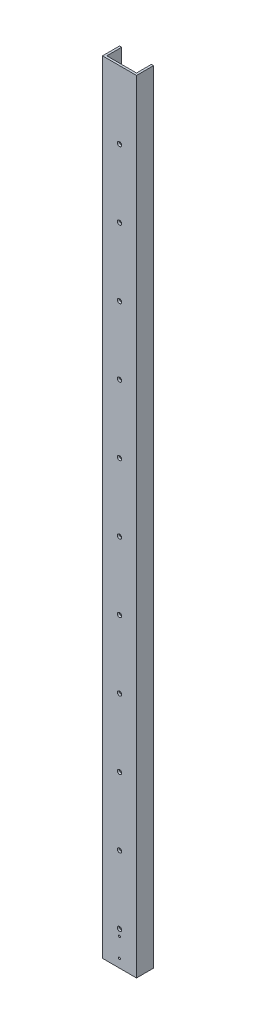
from build123d import *

# Parameters (mm, degrees)
BOSS_EXTRUDE1_DEPTH = 1168.4
CUT_EXTRUDE1_REACH  = 27.4
SKETCH2_R           = 3.175
CUT_EXTRUDE2_REACH  = 27.4
SKETCH4_R           = 1.5875


with BuildPart() as part:
    # Sketch1 → Boss-Extrude1 (new body)
    with BuildSketch(Plane(origin=(0, 0, 0), x_dir=(1, 0, 0), z_dir=(0, 1, 0))):
        Polygon((3.175, 3.175), (3.175, 25.4), (0, 25.4), (0, 0), (50.8, 0), (50.8, 25.4), (47.625, 25.4), (47.625, 3.175), align=None)
    extrude(amount=BOSS_EXTRUDE1_DEPTH)

    # Sketch2 → Cut-Extrude1 (cut, up to next)
    with BuildSketch(Plane.XY, mode=Mode.PRIVATE) as cut_extrude1_sk1:
        with Locations((25.4, 50.8)):
            Circle(SKETCH2_R)
    cut_extrude1_tool1 = extrude(cut_extrude1_sk1.sketch, amount=-CUT_EXTRUDE1_REACH, mode=Mode.PRIVATE) & part.part
    add(cut_extrude1_tool1.solids().sort_by_distance((25.4, 50.8, 0))[0], mode=Mode.SUBTRACT)
    # Sketch2 → Cut-Extrude1 (cut, up to next)
    with BuildSketch(Plane.XY, mode=Mode.PRIVATE) as cut_extrude1_sk2:
        with Locations((25.4, 152.4)):
            Circle(SKETCH2_R)
    cut_extrude1_tool2 = extrude(cut_extrude1_sk2.sketch, amount=-CUT_EXTRUDE1_REACH, mode=Mode.PRIVATE) & part.part
    add(cut_extrude1_tool2.solids().sort_by_distance((25.4, 152.4, 0))[0], mode=Mode.SUBTRACT)
    # Sketch2 → Cut-Extrude1 (cut, up to next)
    with BuildSketch(Plane.XY, mode=Mode.PRIVATE) as cut_extrude1_sk3:
        with Locations((25.4, 254)):
            Circle(SKETCH2_R)
    cut_extrude1_tool3 = extrude(cut_extrude1_sk3.sketch, amount=-CUT_EXTRUDE1_REACH, mode=Mode.PRIVATE) & part.part
    add(cut_extrude1_tool3.solids().sort_by_distance((25.4, 254, 0))[0], mode=Mode.SUBTRACT)
    # Sketch2 → Cut-Extrude1 (cut, up to next)
    with BuildSketch(Plane.XY, mode=Mode.PRIVATE) as cut_extrude1_sk4:
        with Locations((25.4, 355.6)):
            Circle(SKETCH2_R)
    cut_extrude1_tool4 = extrude(cut_extrude1_sk4.sketch, amount=-CUT_EXTRUDE1_REACH, mode=Mode.PRIVATE) & part.part
    add(cut_extrude1_tool4.solids().sort_by_distance((25.4, 355.6, 0))[0], mode=Mode.SUBTRACT)
    # Sketch2 → Cut-Extrude1 (cut, up to next)
    with BuildSketch(Plane.XY, mode=Mode.PRIVATE) as cut_extrude1_sk5:
        with Locations((25.4, 457.2)):
            Circle(SKETCH2_R)
    cut_extrude1_tool5 = extrude(cut_extrude1_sk5.sketch, amount=-CUT_EXTRUDE1_REACH, mode=Mode.PRIVATE) & part.part
    add(cut_extrude1_tool5.solids().sort_by_distance((25.4, 457.2, 0))[0], mode=Mode.SUBTRACT)
    # Sketch2 → Cut-Extrude1 (cut, up to next)
    with BuildSketch(Plane.XY, mode=Mode.PRIVATE) as cut_extrude1_sk6:
        with Locations((25.4, 558.8)):
            Circle(SKETCH2_R)
    cut_extrude1_tool6 = extrude(cut_extrude1_sk6.sketch, amount=-CUT_EXTRUDE1_REACH, mode=Mode.PRIVATE) & part.part
    add(cut_extrude1_tool6.solids().sort_by_distance((25.4, 558.8, 0))[0], mode=Mode.SUBTRACT)
    # Sketch2 → Cut-Extrude1 (cut, up to next)
    with BuildSketch(Plane.XY, mode=Mode.PRIVATE) as cut_extrude1_sk7:
        with Locations((25.4, 660.4)):
            Circle(SKETCH2_R)
    cut_extrude1_tool7 = extrude(cut_extrude1_sk7.sketch, amount=-CUT_EXTRUDE1_REACH, mode=Mode.PRIVATE) & part.part
    add(cut_extrude1_tool7.solids().sort_by_distance((25.4, 660.4, 0))[0], mode=Mode.SUBTRACT)
    # Sketch2 → Cut-Extrude1 (cut, up to next)
    with BuildSketch(Plane.XY, mode=Mode.PRIVATE) as cut_extrude1_sk8:
        with Locations((25.4, 762)):
            Circle(SKETCH2_R)
    cut_extrude1_tool8 = extrude(cut_extrude1_sk8.sketch, amount=-CUT_EXTRUDE1_REACH, mode=Mode.PRIVATE) & part.part
    add(cut_extrude1_tool8.solids().sort_by_distance((25.4, 762, 0))[0], mode=Mode.SUBTRACT)
    # Sketch2 → Cut-Extrude1 (cut, up to next)
    with BuildSketch(Plane.XY, mode=Mode.PRIVATE) as cut_extrude1_sk9:
        with Locations((25.4, 863.6)):
            Circle(SKETCH2_R)
    cut_extrude1_tool9 = extrude(cut_extrude1_sk9.sketch, amount=-CUT_EXTRUDE1_REACH, mode=Mode.PRIVATE) & part.part
    add(cut_extrude1_tool9.solids().sort_by_distance((25.4, 863.6, 0))[0], mode=Mode.SUBTRACT)
    # Sketch2 → Cut-Extrude1 (cut, up to next)
    with BuildSketch(Plane.XY, mode=Mode.PRIVATE) as cut_extrude1_sk10:
        with Locations((25.4, 965.2)):
            Circle(SKETCH2_R)
    cut_extrude1_tool10 = extrude(cut_extrude1_sk10.sketch, amount=-CUT_EXTRUDE1_REACH, mode=Mode.PRIVATE) & part.part
    add(cut_extrude1_tool10.solids().sort_by_distance((25.4, 965.2, 0))[0], mode=Mode.SUBTRACT)
    # Sketch2 → Cut-Extrude1 (cut, up to next)
    with BuildSketch(Plane.XY, mode=Mode.PRIVATE) as cut_extrude1_sk11:
        with Locations((25.4, 1066.8)):
            Circle(SKETCH2_R)
    cut_extrude1_tool11 = extrude(cut_extrude1_sk11.sketch, amount=-CUT_EXTRUDE1_REACH, mode=Mode.PRIVATE) & part.part
    add(cut_extrude1_tool11.solids().sort_by_distance((25.4, 1066.8, 0))[0], mode=Mode.SUBTRACT)

    # Sketch4 → Cut-Extrude2 (cut, up to next)
    with BuildSketch(Plane.XY, mode=Mode.PRIVATE) as cut_extrude2_sk1:
        with Locations((25.4, 41.275)):
            Circle(SKETCH4_R)
    cut_extrude2_tool1 = extrude(cut_extrude2_sk1.sketch, amount=-CUT_EXTRUDE2_REACH, mode=Mode.PRIVATE) & part.part
    add(cut_extrude2_tool1.solids().sort_by_distance((25.4, 41.275, 0))[0], mode=Mode.SUBTRACT)
    # Sketch4 → Cut-Extrude2 (cut, up to next)
    with BuildSketch(Plane.XY, mode=Mode.PRIVATE) as cut_extrude2_sk2:
        with Locations((25.4, 12.7)):
            Circle(SKETCH4_R)
    cut_extrude2_tool2 = extrude(cut_extrude2_sk2.sketch, amount=-CUT_EXTRUDE2_REACH, mode=Mode.PRIVATE) & part.part
    add(cut_extrude2_tool2.solids().sort_by_distance((25.4, 12.7, 0))[0], mode=Mode.SUBTRACT)


solid = part.part
